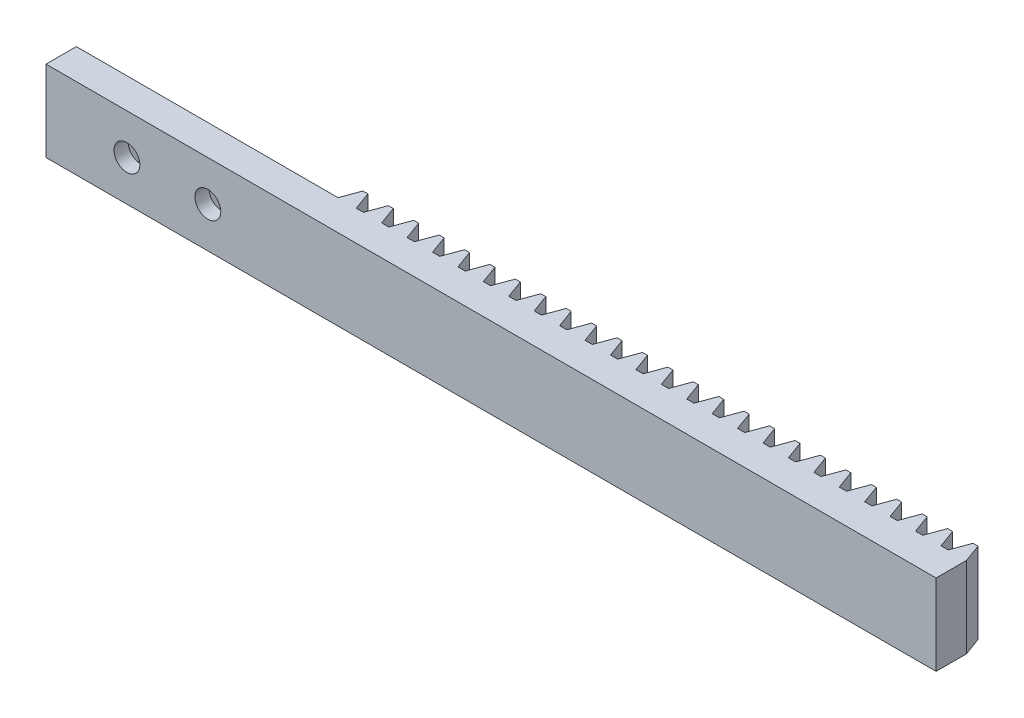
from build123d import *

# Parameters (mm, degrees)
EXTRUDE_1_DEPTH        = 10
EXTRUDE_2_DEPTH        = 10
PATTERN_LINEAR_1_COUNT = 25
PATTERN_LINEAR_1_PITCH = 3.142
SKETCH_2_R             = 1.6
CUT_EXTRUDE_1_DEPTH    = 10
CUT_EXTRUDE_2_DEPTH    = 2


with BuildPart() as part:
    # 草图1 → 凸台-拉伸1 (new body)
    with BuildSketch(Plane(origin=(0, 0, 0), x_dir=(1, 0, 0), z_dir=(0, 1, 0))):
        Polygon((0, 3.75), (0, 0), (110, 0), (110, 3.75), (107.747407554, 3.75), align=None)
    extrude(amount=EXTRUDE_1_DEPTH)

    # 草图1<5> → 凸台-拉伸2 (add)
    with BuildSketch(Plane(origin=(0, 0, 0), x_dir=(1, 0, 0), z_dir=(0, 1, 0))):
        Polygon((107.747407554, 3.75), (110, 3.75), (109.181203777, 5.999624134), (108.566203777, 5.999624134), align=None)
    extrude_2 = extrude(amount=EXTRUDE_2_DEPTH)

    # 阵列(线性)1: 凸台-拉伸2 ×25
    with Locations(*[(-i * PATTERN_LINEAR_1_PITCH, 0, 0) for i in range(1, PATTERN_LINEAR_1_COUNT)]):
        add(extrude_2)

    # 草图2 → 切除-拉伸1 (cut)
    with BuildSketch(Plane(origin=(0, 0, -3.75), x_dir=(-1, 0, 0), z_dir=(0, 0, -1))):
        with Locations((-10, 5)):
            Circle(SKETCH_2_R)
        with Locations((-20, 5)):
            Circle(SKETCH_2_R)
    extrude(amount=-CUT_EXTRUDE_1_DEPTH, mode=Mode.SUBTRACT)

    # 草图3 → 切除-拉伸2 (cut)
    with BuildSketch(Plane(origin=(0, 0, -3.75), x_dir=(-1, 0, 0), z_dir=(0, 0, -1))):
        Polygon((-21.58771324, 7.75), (-23.175426481, 5), (-21.58771324, 2.25), (-18.41228676, 2.25), (-16.824573519, 5), (-18.41228676, 7.75), align=None)
        Polygon((-11.58771324, 7.75), (-13.175426481, 5), (-11.58771324, 2.25), (-8.41228676, 2.25), (-6.824573519, 5), (-8.41228676, 7.75), align=None)
    extrude(amount=-CUT_EXTRUDE_2_DEPTH, mode=Mode.SUBTRACT)


solid = part.part
